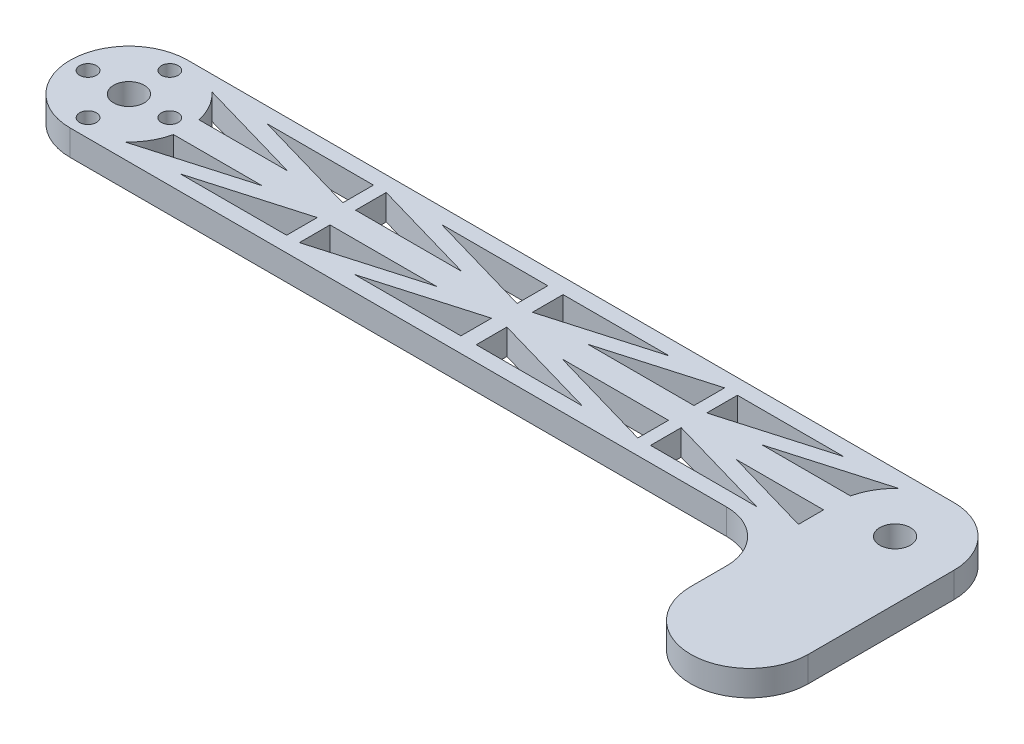
from build123d import *

# Parameters (mm, degrees)
SKETCH1_R           = 1.65
SKETCH1_R_2         = 3
BOSS_EXTRUDE1_DEPTH = 5
CUT_EXTRUDE1_DEPTH  = 5
SKETCH3_R           = 3
BOSS_EXTRUDE2_DEPTH = 5
FILLET1_R           = 10


with BuildPart() as part:
    # Sketch1 → Boss-Extrude1 (new body)
    with BuildSketch(Plane(origin=(0, 0, 0), x_dir=(1, 0, 0), z_dir=(0, 1, 0))):
        with BuildLine():
            Line((-75, 11.5), (75, 11.5))
            ThreePointArc((75, 11.5), (86.5, 0), (75, -11.5))
            Line((75, -11.5), (-75, -11.5))
            ThreePointArc((-75, -11.5), (-86.5, 0), (-75, 11.5))
        make_face()
        with Locations((-75, 8)):
            Circle(SKETCH1_R, mode=Mode.SUBTRACT)
        with Locations((-67, 0)):
            Circle(SKETCH1_R, mode=Mode.SUBTRACT)
        with Locations((-75, -8)):
            Circle(SKETCH1_R, mode=Mode.SUBTRACT)
        with Locations((-83, 0)):
            Circle(SKETCH1_R, mode=Mode.SUBTRACT)
        with Locations((75, 0)):
            Circle(SKETCH1_R_2, mode=Mode.SUBTRACT)
        with Locations((-75, 0)):
            Circle(SKETCH1_R_2, mode=Mode.SUBTRACT)
    extrude(amount=BOSS_EXTRUDE1_DEPTH)

    # Sketch2 → Cut-Extrude1 (cut)
    with BuildSketch(Plane(origin=(0, 5, 0), x_dir=(1, 0, 0), z_dir=(0, 1, 0))):
        with BuildLine():
            Line((-63.77502784, 2.5), (-46.452027549, 2.5))
            Line((-46.452027549, 2.5), (-67.254033308, 8.5))
            ThreePointArc((-67.254033308, 8.5), (-65.051425718, 5.768524054), (-63.77502784, 2.5))
        make_face()
        Polygon((-56.429022412, 8.5), (-35.627016654, 2.5), (-35.627016654, 8.5), align=None)
        Polygon((-12.325010896, 2.5), (-33.127016654, 8.5), (-33.127016654, 2.5), align=None)
        Polygon((-1.5, 8.5), (-22.302005758, 8.5), (-1.5, 2.5), align=None)
        Polygon((-1.5, -2.5), (-1.5, -8.5), (-22.302005758, -8.5), align=None)
        Polygon((-33.127016654, -2.5), (-12.325010896, -2.5), (-33.127016654, -8.5), align=None)
        Polygon((-35.627016654, -2.5), (-35.627016654, -8.5), (-56.429022412, -8.5), align=None)
        with BuildLine():
            Line((-46.452027549, -2.5), (-67.254033308, -8.5))
            ThreePointArc((-67.254033308, -8.5), (-65.051425718, -5.768524054), (-63.77502784, -2.5))
            Line((-63.77502784, -2.5), (-46.452027549, -2.5))
        make_face()
        Polygon((22.302005758, -8.5), (1.5, -2.5), (1.5, -8.5), align=None)
        Polygon((33.127016654, -8.5), (33.127016654, -2.5), (12.325010896, -2.5), align=None)
        Polygon((56.429022412, -8.5), (35.627016654, -2.5), (35.627016654, -8.5), align=None)
        with BuildLine():
            Line((46.452027549, -2.5), (67.254033308, -8.5))
            ThreePointArc((67.254033308, -8.5), (65.051425718, -5.768524054), (63.77502784, -2.5))
            Line((63.77502784, -2.5), (46.452027549, -2.5))
        make_face()
        with BuildLine():
            Line((46.452027549, 2.5), (67.254033308, 8.5))
            ThreePointArc((67.254033308, 8.5), (65.051425718, 5.768524054), (63.77502784, 2.5))
            Line((63.77502784, 2.5), (46.452027549, 2.5))
        make_face()
        Polygon((35.627016654, 2.5), (35.627016654, 8.5), (56.429022412, 8.5), align=None)
        Polygon((33.127016654, 2.5), (12.325010896, 2.5), (33.127016654, 8.5), align=None)
        Polygon((1.5, 2.5), (1.5, 8.5), (22.302005758, 8.5), align=None)
    extrude(amount=-CUT_EXTRUDE1_DEPTH, mode=Mode.SUBTRACT)

    # Sketch3 → Boss-Extrude2 (add, through all)
    with BuildSketch(Plane(origin=(0, 5, 0), x_dir=(1, 0, 0), z_dir=(0, 1, 0))):
        with BuildLine():
            Line((86.5, 0), (86.5, -28.5))
            ThreePointArc((86.5, -28.5), (75, -40), (63.5, -28.5))
            Line((63.5, -28.5), (63.5, 0))
            ThreePointArc((63.5, 0), (75, 11.5), (86.5, 0))
        make_face()
        with Locations((75, 0)):
            Circle(SKETCH3_R, mode=Mode.SUBTRACT)
    extrude(amount=-BOSS_EXTRUDE2_DEPTH)

    # Fillet1
    fillet1_edges = [part.edges().sort_by_distance(p)[0] for p in [
        (63.5, 2.5, 11.5),
    ]]
    fillet(fillet1_edges, radius=FILLET1_R)


solid = part.part
